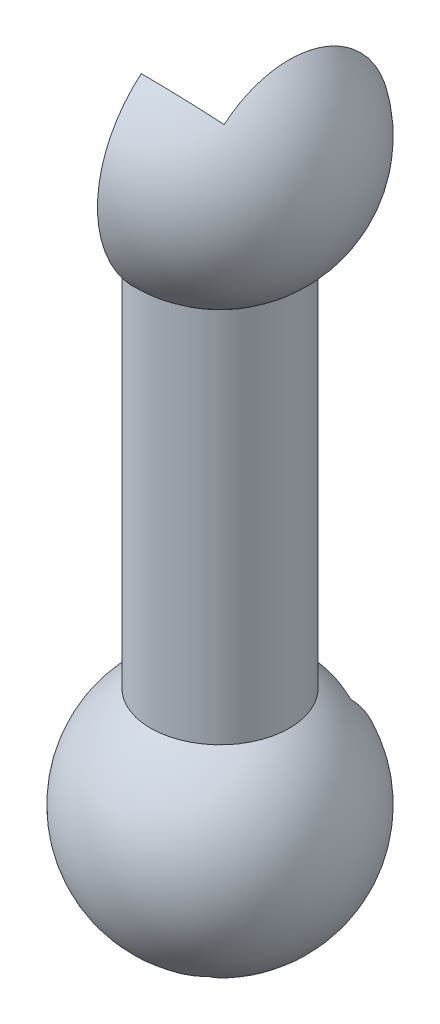
from build123d import *

# Parameters (mm, degrees)
SKETCH_7_R                = 30
SKETCH_7_R_2              = 2
EXTRUDE_1_DEPTH           = 178.35
REVOLVE_1_ANGLE           = 180
SKETCH_13_W               = 62
SKETCH_13_H               = 63.428923534
REVOLVE_2_ANGLE           = 130
REVOLVE_2_OTHER_WAY_ANGLE = 53
SKETCH_19_W               = 45
SKETCH_19_H               = 76.537430518
REVOLVE_4_ANGLE           = 45
REVOLVE_4_OTHER_WAY_ANGLE = 125


with BuildPart() as part:
    # 草图7 → 凸台-拉伸1 (new body)
    with BuildSketch(Plane(origin=(0, 0, 0), x_dir=(1, 0, 0), z_dir=(0, 1, 0))):
        Circle(SKETCH_7_R)
        with Locations((5, 5)):
            Circle(SKETCH_7_R_2, mode=Mode.SUBTRACT)
        with Locations((5, -5)):
            Circle(SKETCH_7_R_2, mode=Mode.SUBTRACT)
        with Locations((-5, -5)):
            Circle(SKETCH_7_R_2, mode=Mode.SUBTRACT)
        with Locations((-5, 5)):
            Circle(SKETCH_7_R_2, mode=Mode.SUBTRACT)
        with BuildLine():
            Line((7.031506006, 8.445719569), (18.371677247, 19.78589081))
            ThreePointArc((18.371677247, 19.78589081), (0, 27), (-18.371677247, 19.78589081))
            Line((-18.371677247, 19.78589081), (-7.031506006, 8.445719569))
            ThreePointArc((-7.031506006, 8.445719569), (-3.469266271, 8.69551813), (-1.127016654, 6))
            Line((-1.127016654, 6), (1.127016654, 6))
            ThreePointArc((1.127016654, 6), (3.469266271, 8.69551813), (7.031506006, 8.445719569))
        make_face(mode=Mode.SUBTRACT)
        with BuildLine():
            Line((8.445719569, 7.031506006), (19.78589081, 18.371677247))
            ThreePointArc((19.78589081, 18.371677247), (27, 0), (19.78589081, -18.371677247))
            Line((19.78589081, -18.371677247), (8.445719569, -7.031506006))
            ThreePointArc((8.445719569, -7.031506006), (8.69551813, -3.469266271), (6, -1.127016654))
            Line((6, -1.127016654), (6, 1.127016654))
            ThreePointArc((6, 1.127016654), (8.69551813, 3.469266271), (8.445719569, 7.031506006))
        make_face(mode=Mode.SUBTRACT)
        with BuildLine():
            Line((7.031506006, -8.445719569), (18.371677247, -19.78589081))
            ThreePointArc((18.371677247, -19.78589081), (0, -27), (-18.371677247, -19.78589081))
            Line((-18.371677247, -19.78589081), (-7.031506006, -8.445719569))
            ThreePointArc((-7.031506006, -8.445719569), (-3.469266271, -8.69551813), (-1.127016654, -6))
            Line((-1.127016654, -6), (1.127016654, -6))
            ThreePointArc((1.127016654, -6), (3.469266271, -8.69551813), (7.031506006, -8.445719569))
        make_face(mode=Mode.SUBTRACT)
        with BuildLine():
            Line((-8.445719569, -7.031506006), (-19.78589081, -18.371677247))
            ThreePointArc((-19.78589081, -18.371677247), (-27, 0), (-19.78589081, 18.371677247))
            Line((-19.78589081, 18.371677247), (-8.445719569, 7.031506006))
            ThreePointArc((-8.445719569, 7.031506006), (-8.69551813, 3.469266271), (-6, 1.127016654))
            Line((-6, 1.127016654), (-6, -1.127016654))
            ThreePointArc((-6, -1.127016654), (-8.69551813, -3.469266271), (-8.445719569, -7.031506006))
        make_face(mode=Mode.SUBTRACT)
        with BuildLine():
            Line((1.127016654, 4), (-1.127016654, 4))
            ThreePointArc((-1.127016654, 4), (-2.171572875, 2.171572875), (-4, 1.127016654))
            Line((-4, 1.127016654), (-4, -1.127016654))
            ThreePointArc((-4, -1.127016654), (-2.171572875, -2.171572875), (-1.127016654, -4))
            Line((-1.127016654, -4), (1.127016654, -4))
            ThreePointArc((1.127016654, -4), (2.171572875, -2.171572875), (4, -1.127016654))
            Line((4, -1.127016654), (4, 1.127016654))
            ThreePointArc((4, 1.127016654), (2.171572875, 2.171572875), (1.127016654, 4))
        make_face(mode=Mode.SUBTRACT)
    extrude(amount=EXTRUDE_1_DEPTH)


with BuildPart() as body_2:
    # 草图8 → 旋转1 (revolve)
    with BuildSketch(Plane(origin=(0, 0, 0), x_dir=(0, 0, -1), z_dir=(1, 0, 0))):
        with BuildLine():
            Line((0, 263.35), (0, 260.35))
            ThreePointArc((0, 260.35), (47.434164903, 226.161388301), (30, 170.35))
            Line((30, 170.35), (30, 166.65789545))
            ThreePointArc((30, 166.65789545), (50.619569048, 226.055388547), (0, 263.35))
        make_face()
    revolve(axis=Axis((0, 210.35, 0), (0, -1, 0)), revolution_arc=REVOLVE_1_ANGLE)


with BuildPart() as body_3:
    # 草图13 → 旋转2 (revolve)
    with BuildSketch(Plane(origin=(0, 210.35, 0), x_dir=(1, 0, 0), z_dir=(0, 1, 0))):
        with Locations((-1.07172831, 63.714461767)):
            Rectangle(SKETCH_13_W, SKETCH_13_H)
    revolve(axis=Axis((-30.13148335, 210.35, 0), (1, 0, 0)), revolution_arc=REVOLVE_2_ANGLE)

    # 草图13 → 旋转2 other way (revolve)
    with BuildSketch(Plane(origin=(0, 210.35, 0), x_dir=(1, 0, 0), z_dir=(0, 1, 0))):
        with Locations((-1.07172831, 63.714461767)):
            Rectangle(SKETCH_13_W, SKETCH_13_H)
    revolve(axis=Axis((-30.13148335, 210.35, 0), (-1, 0, 0)), revolution_arc=REVOLVE_2_OTHER_WAY_ANGLE)


with BuildPart() as body_2_1:
    add(body_2.part)

    # Combine 1: cut body 3
    add(body_3.part, mode=Mode.SUBTRACT)


with BuildPart() as body_3_2:
    # 草图17 → 旋转3 (revolve)
    with BuildSketch(Plane(origin=(0, 0, 0), x_dir=(0, 0, -1), z_dir=(1, 0, 0))):
        with BuildLine():
            Line((0, -90), (0, -93))
            ThreePointArc((0, -93), (50.619569048, -55.705388547), (30, 3.69210455))
            Line((30, 3.69210455), (30, 0))
            ThreePointArc((30, 0), (47.434164903, -55.811388301), (0, -90))
        make_face()
    revolve(axis=Axis((0, 0, 0), (0, -1, 0)))


with BuildPart() as body_4:
    # 草图19 → 旋转4 (revolve)
    with BuildSketch(Plane(origin=(0, -40, 0), x_dir=(1, 0, 0), z_dir=(0, 1, 0))):
        with Locations((0, 38.268715259)):
            Rectangle(SKETCH_19_W, SKETCH_19_H)
    revolve(axis=Axis((-67.878952915, -40, 0), (1, 0, 0)), revolution_arc=REVOLVE_4_ANGLE)

    # 草图19 → 旋转4 other way (revolve)
    with BuildSketch(Plane(origin=(0, -40, 0), x_dir=(1, 0, 0), z_dir=(0, 1, 0))):
        with Locations((0, 38.268715259)):
            Rectangle(SKETCH_19_W, SKETCH_19_H)
    revolve(axis=Axis((-67.878952915, -40, 0), (-1, 0, 0)), revolution_arc=REVOLVE_4_OTHER_WAY_ANGLE)


with BuildPart() as body_3_2_1:
    add(body_3_2.part)

    # Combine 2: cut body 4
    add(body_4.part, mode=Mode.SUBTRACT)


solid = Compound([part.part, body_2_1.part, body_3_2_1.part])
